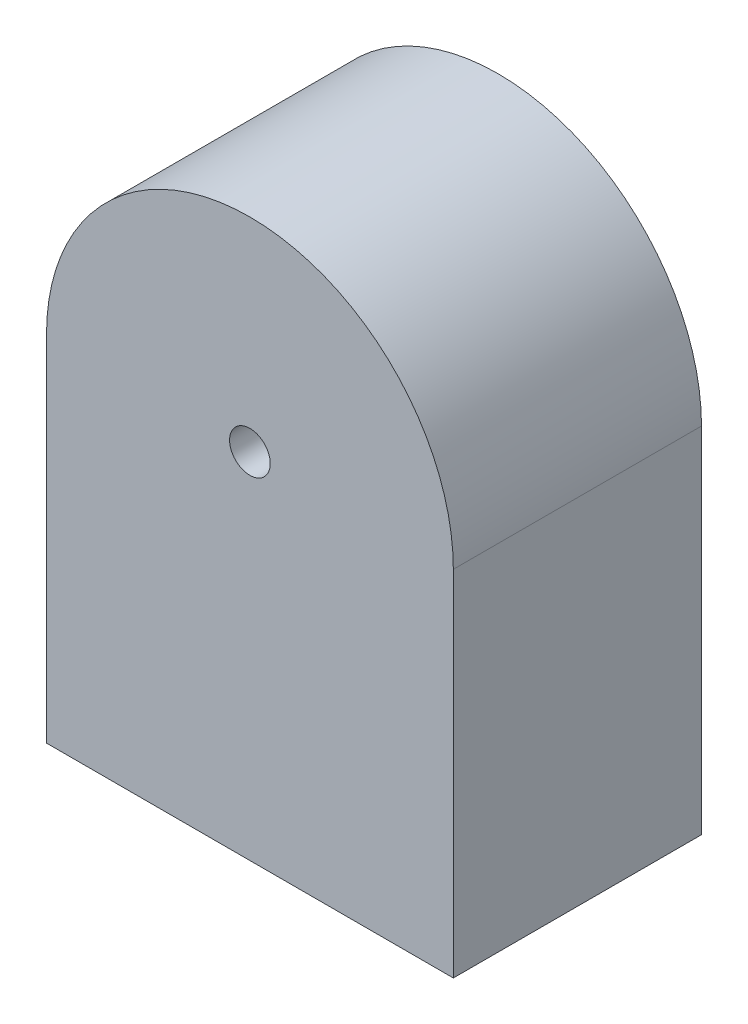
from build123d import *

# Parameters (mm, degrees)
SKETCH1_R           = 1.5
BOSS_EXTRUDE1_DEPTH = 18.3


with BuildPart() as part:
    # Sketch1 → Boss-Extrude1 (new body)
    with BuildSketch(Plane.XY):
        with BuildLine():
            Line((-15, 0), (-15, -26.1))
            Line((-15, -26.1), (15, -26.1))
            Line((15, -26.1), (15, 0))
            ThreePointArc((15, 0), (0, 15), (-15, 0))
        make_face()
        Circle(SKETCH1_R, mode=Mode.SUBTRACT)
    extrude(amount=BOSS_EXTRUDE1_DEPTH)


solid = part.part
